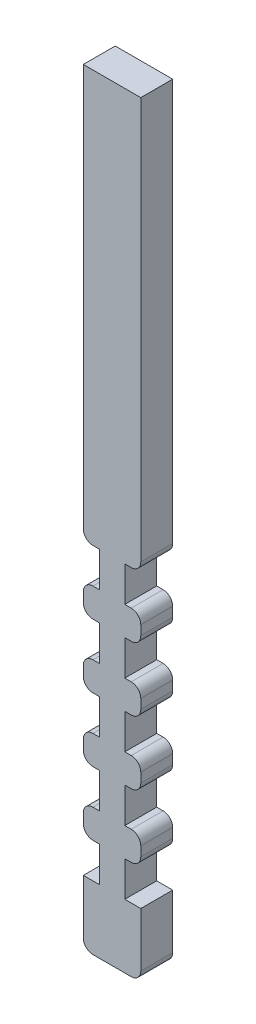
from build123d import *

# Parameters (mm, degrees)
BOSS_EXTRUDE1_DEPTH = 10
FILLET1_R           = 3
SKETCH2_W           = 18
SKETCH2_H           = 10
BOSS_EXTRUDE2_DEPTH = 120


with BuildPart() as part:
    # Sketch1 → Boss-Extrude1 (new body)
    with BuildSketch(Plane.XY):
        Polygon((-9, 0), (9, 0), (9, 20), (3.99, 20), (3.99, 31), (9, 31), (9, 40), (3.99, 40), (3.99, 51), (9, 51), (9, 60), (3.99, 60), (3.99, 71), (9, 71), (9, 80), (3.99, 80), (3.99, 91), (9, 91), (9, 100), (3.99, 100), (3.99, 111), (9, 111), (9, 120), (3.99, 120), (-3.99, 120), (-9, 120), (-9, 111), (-3.99, 111), (-3.99, 100), (-9, 100), (-9, 91), (-3.99, 91), (-3.99, 80), (-9, 80), (-9, 71), (-3.99, 71), (-3.99, 60), (-9, 60), (-9, 51), (-3.99, 51), (-3.99, 40), (-9, 40), (-9, 31), (-3.99, 31), (-3.99, 20), (-9, 20), align=None)
    extrude(amount=BOSS_EXTRUDE1_DEPTH)

    # Fillet1
    fillet1_edges = [part.edges().sort_by_distance(p)[0] for p in [
        (-9, 31, 5),
        (-9, 40, 5),
        (-9, 51, 5),
        (-9, 60, 5),
        (-9, 71, 5),
        (-9, 80, 5),
        (-9, 91, 5),
        (-9, 100, 5),
        (-9, 111, 5),
        (9, 111, 5),
        (9, 100, 5),
        (9, 91, 5),
        (9, 80, 5),
        (9, 71, 5),
        (9, 60, 5),
        (9, 51, 5),
        (9, 40, 5),
        (9, 31, 5),
        (9, 0, 5),
        (-9, 0, 5),
    ]]
    fillet(fillet1_edges, radius=FILLET1_R)

    # Sketch2 → Boss-Extrude2 (add)
    with BuildSketch(Plane(origin=(0, 120, 0), x_dir=(1, 0, 0), z_dir=(0, 1, 0))):
        with Locations((0, -5)):
            Rectangle(SKETCH2_W, SKETCH2_H)
    extrude(amount=BOSS_EXTRUDE2_DEPTH)


solid = part.part
